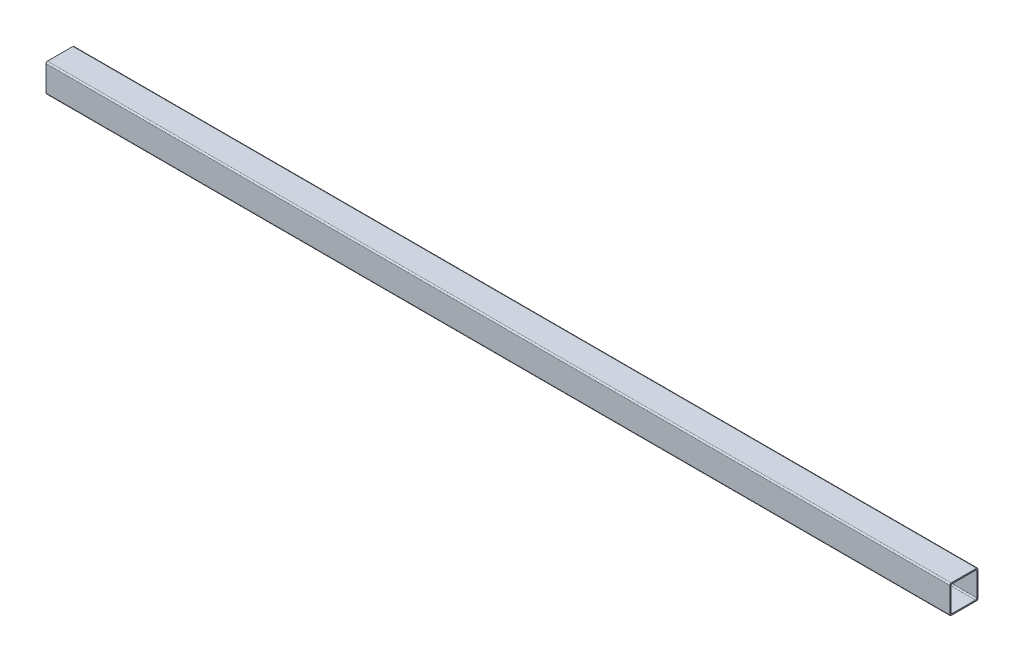
from build123d import *

# Parameters (mm, degrees)
BOSS_EXTRUDE1_DEPTH      = 914.4
BOSS_EXTRUDE1_DEPTH_BACK = 914.4
SKETCH5_W                = 609.6
SKETCH5_H                = 38.1
CUT_EXTRUDE1_DEPTH       = 39.1


with BuildPart() as part:
    # Sketch4 → Boss-Extrude1 (new body, two sides)
    with BuildSketch(Plane(origin=(0, 0, 0), x_dir=(0, 0, -1), z_dir=(1, 0, 0))) as boss_extrude1_sk:
        with BuildLine():
            Line((19.05, -17.145), (19.05, 17.145))
            ThreePointArc((19.05, 17.145), (18.492038418, 18.492038418), (17.145, 19.05))
            Line((17.145, 19.05), (-17.145, 19.05))
            ThreePointArc((-17.145, 19.05), (-18.492038418, 18.492038418), (-19.05, 17.145))
            Line((-19.05, 17.145), (-19.05, -17.145))
            ThreePointArc((-19.05, -17.145), (-18.492038418, -18.492038418), (-17.145, -19.05))
            Line((-17.145, -19.05), (17.145, -19.05))
            ThreePointArc((17.145, -19.05), (18.492038418, -18.492038418), (19.05, -17.145))
        make_face()
        with BuildLine():
            Line((17.399, 15.6591), (17.399, -15.6591))
            ThreePointArc((17.399, -15.6591), (16.889395089, -16.889395089), (15.6591, -17.399))
            Line((15.6591, -17.399), (-15.6591, -17.399))
            ThreePointArc((-15.6591, -17.399), (-16.889395089, -16.889395089), (-17.399, -15.6591))
            Line((-17.399, -15.6591), (-17.399, 15.6591))
            ThreePointArc((-17.399, 15.6591), (-16.889395089, 16.889395089), (-15.6591, 17.399))
            Line((-15.6591, 17.399), (15.6591, 17.399))
            ThreePointArc((15.6591, 17.399), (16.889395089, 16.889395089), (17.399, 15.6591))
        make_face(mode=Mode.SUBTRACT)
    extrude(amount=BOSS_EXTRUDE1_DEPTH)
    extrude(boss_extrude1_sk.sketch, amount=-BOSS_EXTRUDE1_DEPTH_BACK)

    # Sketch5 → Cut-Extrude1 (cut, through all)
    with BuildSketch(Plane.XZ.offset(19.05)):
        with Locations((-609.6, 0)):
            Rectangle(SKETCH5_W, SKETCH5_H)
    extrude(amount=-CUT_EXTRUDE1_DEPTH, mode=Mode.SUBTRACT)


solid = part.part
